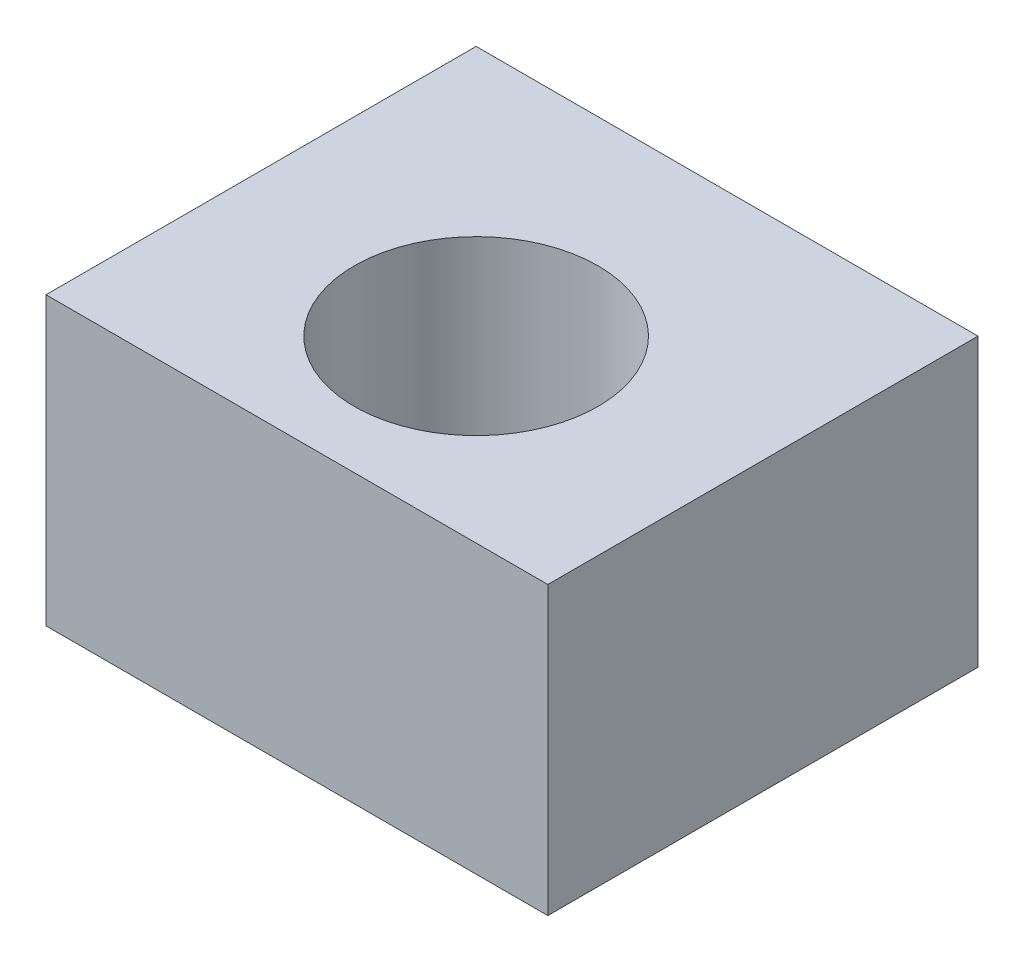
from build123d import *

# Parameters (mm, degrees)
SKETCH1_W             = 35
SKETCH1_H             = 35
BOSS_EXTRUDE1_DEPTH   = 20
SKETCH2_W             = 35
SKETCH2_H             = 7
BOSS_EXTRUDE2_DEPTH   = 27
SKETCH3_R             = 8.5
CUT_EXTRUDE1_DEPTH    = 20
CUT_EXTRUDE3_REACH    = 22
SKETCH7_W             = 35
SKETCH7_H             = 5
SKETCH9_W             = 7
SKETCH9_H             = 27
CUT_EXTRUDE4_DEPTH    = 40
M3_TAPPED_HOLE3_D     = 2.5
M3_TAPPED_HOLE3_DEPTH = 7.5
M3_TAPPED_HOLE3_TIP   = 0.751075774


with BuildPart() as part:
    # Sketch1 → Boss-Extrude1 (new body)
    with BuildSketch(Plane(origin=(0, 0, 0), x_dir=(1, 0, 0), z_dir=(0, 1, 0))):
        Rectangle(SKETCH1_W, SKETCH1_H)
    extrude(amount=BOSS_EXTRUDE1_DEPTH)

    # Sketch2 → Boss-Extrude2 (add)
    with BuildSketch(Plane(origin=(0, 20, 0), x_dir=(1, 0, 0), z_dir=(0, 1, 0))):
        with Locations((0, 14)):
            Rectangle(SKETCH2_W, SKETCH2_H)
    extrude(amount=BOSS_EXTRUDE2_DEPTH)

    # Sketch3 → Cut-Extrude1 (cut)
    with BuildSketch(Plane.XZ):
        Circle(SKETCH3_R)
    extrude(amount=-CUT_EXTRUDE1_DEPTH, mode=Mode.SUBTRACT)

    # Sketch7 → Cut-Extrude3 (cut, up to next)
    with BuildSketch(Plane(origin=(0, 20, 0), x_dir=(1, 0, 0), z_dir=(0, 1, 0)), mode=Mode.PRIVATE) as cut_extrude3_sk1:
        with Locations((0, -15)):
            Rectangle(SKETCH7_W, SKETCH7_H)
    cut_extrude3_tool1 = extrude(cut_extrude3_sk1.sketch, amount=-CUT_EXTRUDE3_REACH, mode=Mode.PRIVATE) & part.part
    add(cut_extrude3_tool1.solids().sort_by_distance((0, 20, 15))[0], mode=Mode.SUBTRACT)

    # Sketch9 → Cut-Extrude4 (cut)
    with BuildSketch(Plane.ZY.offset(17.5)):
        with Locations((-14, 33.5)):
            Rectangle(SKETCH9_W, SKETCH9_H)
    extrude(amount=-CUT_EXTRUDE4_DEPTH, mode=Mode.SUBTRACT)

    # M3 Tapped Hole3
    with Locations(Plane(origin=(0, 0, 0), x_dir=(-1, 0, 0), z_dir=(0, -1, 0))):
        with Locations((12.5, 5.5), (-12.5, 5.5), (-12.5, -9.5), (12.5, -9.5)):
            Hole(M3_TAPPED_HOLE3_D / 2, depth=M3_TAPPED_HOLE3_DEPTH)
            with Locations((0, 0, -(M3_TAPPED_HOLE3_DEPTH + M3_TAPPED_HOLE3_TIP / 2))):  # 118° drill point
                Cone(0, M3_TAPPED_HOLE3_D / 2, M3_TAPPED_HOLE3_TIP, mode=Mode.SUBTRACT)


solid = part.part
